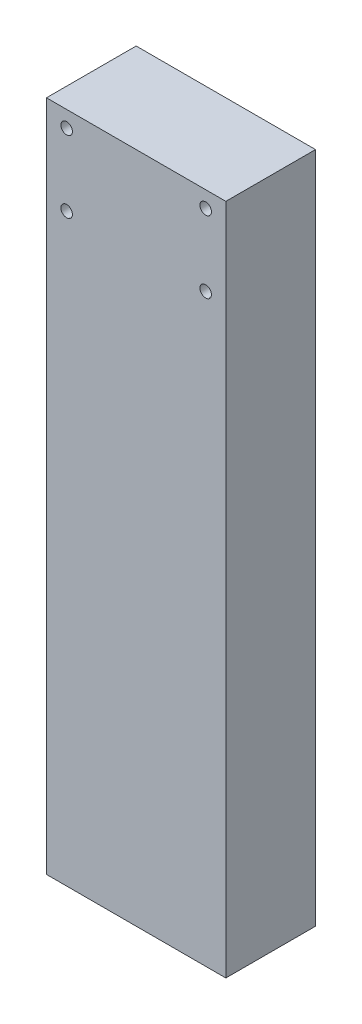
from build123d import *

# Parameters (mm, degrees)
SKETCH1_W               = 101.6
SKETCH1_H               = 50.8
BOSS_EXTRUDE1_DEPTH     = 381
F_1_4_CLEARANCE_HOLE2_D = 6.5278


with BuildPart() as part:
    # Sketch1 → Boss-Extrude1 (new body)
    with BuildSketch(Plane(origin=(0, 0, 0), x_dir=(1, 0, 0), z_dir=(0, 1, 0))):
        Rectangle(SKETCH1_W, SKETCH1_H)
    extrude(amount=BOSS_EXTRUDE1_DEPTH)

    # 1/4 Clearance Hole2 (through all)
    with Locations(Plane(origin=(0, 128.0439367, 25.4), x_dir=(1, 0, 0), z_dir=(0, 0, 1))):
        with Locations((39.37, 243.7168133), (39.37, 203.0768133), (-39.37, 203.0768133), (-39.37, 243.7168133)):
            Hole(F_1_4_CLEARANCE_HOLE2_D / 2)


solid = part.part
